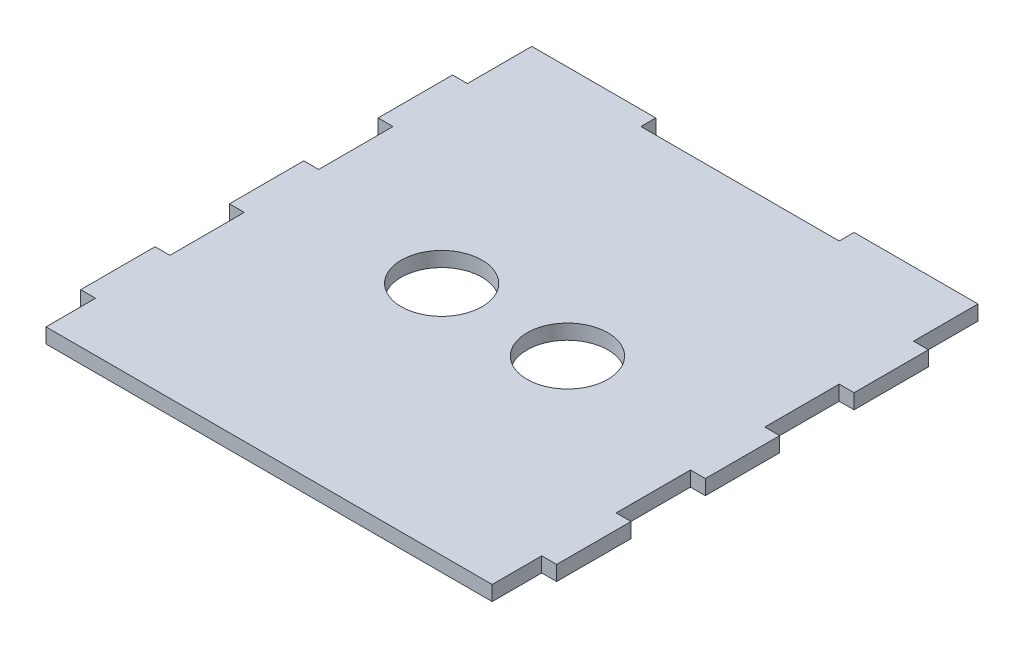
from build123d import *

# Parameters (mm, degrees)
SKETCH1_W           = 90
SKETCH1_H           = 95
BOSS_EXTRUDE1_DEPTH = 3
SKETCH4_W           = 3
SKETCH4_H           = 15
BOSS_EXTRUDE4_DEPTH = 3
SKETCH5_W           = 90
SKETCH5_H           = 3
BOSS_EXTRUDE5_DEPTH = 3
SKETCH6_W           = 40
SKETCH6_H           = 3
CUT_EXTRUDE2_DEPTH  = 4
SKETCH8_R           = 8.15
CUT_EXTRUDE3_DEPTH  = 4


with BuildPart() as part:
    # Sketch1 → Boss-Extrude1 (new body)
    with BuildSketch(Plane(origin=(0, 0, 0), x_dir=(1, 0, 0), z_dir=(0, 1, 0))):
        with Locations((45, 47.5)):
            Rectangle(SKETCH1_W, SKETCH1_H)
    extrude(amount=BOSS_EXTRUDE1_DEPTH)

    # Sketch4 → Boss-Extrude4 (add)
    with BuildSketch(Plane(origin=(0, 3, 0), x_dir=(1, 0, 0), z_dir=(0, 1, 0))):
        with Locations((-1.5, 77.5)):
            Rectangle(SKETCH4_W, SKETCH4_H)
        with Locations((-1.5, 47.5)):
            Rectangle(SKETCH4_W, SKETCH4_H)
        with Locations((-1.5, 17.5)):
            Rectangle(SKETCH4_W, SKETCH4_H)
        with Locations((91.5, 77.5)):
            Rectangle(SKETCH4_W, SKETCH4_H)
        with Locations((91.5, 47.5)):
            Rectangle(SKETCH4_W, SKETCH4_H)
        with Locations((91.5, 17.5)):
            Rectangle(SKETCH4_W, SKETCH4_H)
    extrude(amount=-BOSS_EXTRUDE4_DEPTH)

    # Sketch5 → Boss-Extrude5 (add)
    with BuildSketch(Plane(origin=(0, 3, 0), x_dir=(1, 0, 0), z_dir=(0, 1, 0))):
        with Locations((45, 96.5)):
            Rectangle(SKETCH5_W, SKETCH5_H)
    extrude(amount=-BOSS_EXTRUDE5_DEPTH)

    # Sketch6 → Cut-Extrude2 (cut)
    with BuildSketch(Plane(origin=(0, 3, 0), x_dir=(1, 0, 0), z_dir=(0, 1, 0))):
        with Locations((45, 96.5)):
            Rectangle(SKETCH6_W, SKETCH6_H)
    extrude(amount=-CUT_EXTRUDE2_DEPTH, mode=Mode.SUBTRACT)

    # Sketch8 → Cut-Extrude3 (cut, through all)
    with BuildSketch(Plane(origin=(0, 3, 0), x_dir=(1, 0, 0), z_dir=(0, 1, 0))):
        with Locations((32.31, 47.5)):
            Circle(SKETCH8_R)
        with Locations((57.69, 47.5)):
            Circle(SKETCH8_R)
    extrude(amount=-CUT_EXTRUDE3_DEPTH, mode=Mode.SUBTRACT)


solid = part.part
